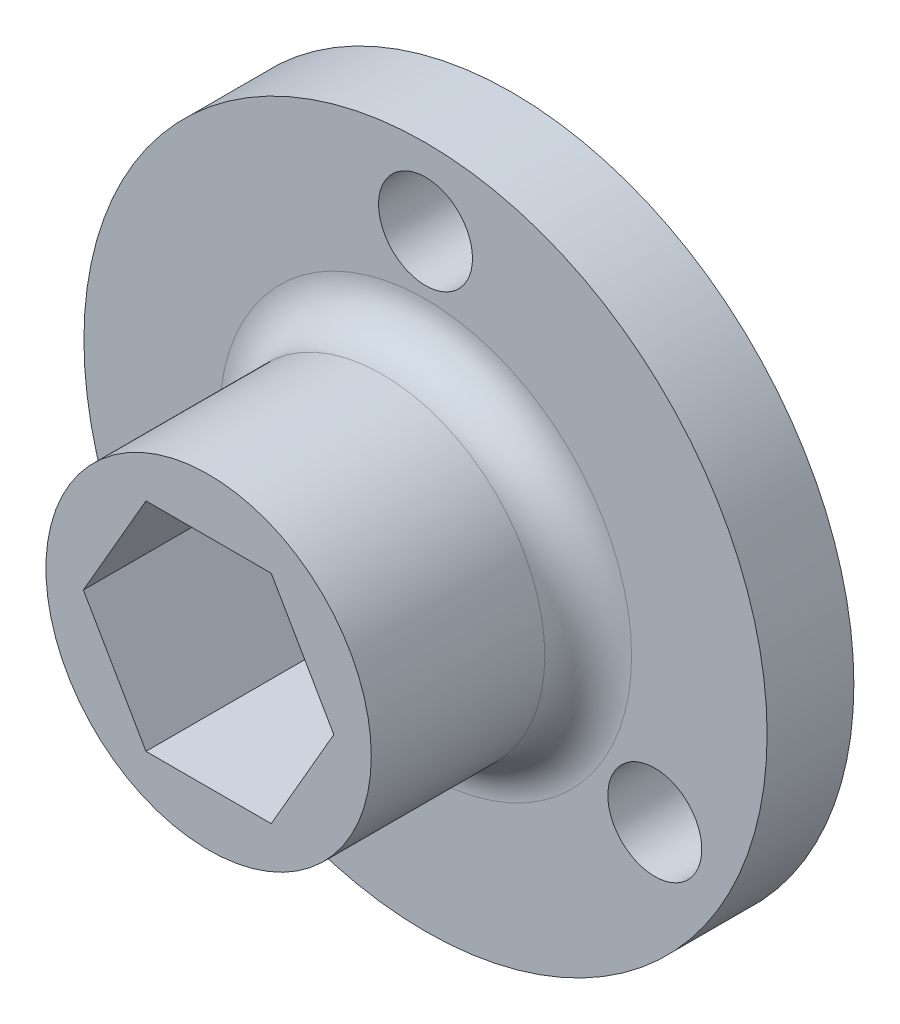
from build123d import *

# Parameters (mm, degrees)
SKETCH1_R            = 20
BOSS_EXTRUDE1_DEPTH  = 5.08
SKETCH2_R            = 9.525
BOSS_EXTRUDE2_DEPTH  = 12.7
M5_CLEARANCE_HOLE1_D = 5.5
CUT_EXTRUDE1_DEPTH   = 18.78
FILLET1_R            = 2.54


with BuildPart() as part:
    # Sketch1 → Boss-Extrude1 (new body)
    with BuildSketch(Plane.XY):
        Circle(SKETCH1_R)
    extrude(amount=BOSS_EXTRUDE1_DEPTH)

    # Sketch2 → Boss-Extrude2 (add)
    with BuildSketch(Plane.XY.offset(5.08)):
        Circle(SKETCH2_R)
    extrude(amount=BOSS_EXTRUDE2_DEPTH)

    # M5 Clearance Hole1 (through all)
    with Locations(Plane.XY.offset(5.08)):
        with Locations((0, 15.5), (13.423393759, -7.75), (-13.423393759, -7.75)):
            Hole(M5_CLEARANCE_HOLE1_D / 2)

    # Sketch5 → Cut-Extrude1 (cut, through all)
    with BuildSketch(Plane.XY.offset(17.78)):
        Polygon((3.666174209, 6.35), (-3.666174209, 6.35), (-7.332348419, 0), (-3.666174209, -6.35), (3.666174209, -6.35), (7.332348419, 0), align=None)
    extrude(amount=-CUT_EXTRUDE1_DEPTH, mode=Mode.SUBTRACT)

    # Fillet1
    fillet1_edges = [part.edges().sort_by_distance(p)[0] for p in [
        (-9.525, 0, 5.08),
    ]]
    fillet(fillet1_edges, radius=FILLET1_R)


solid = part.part
